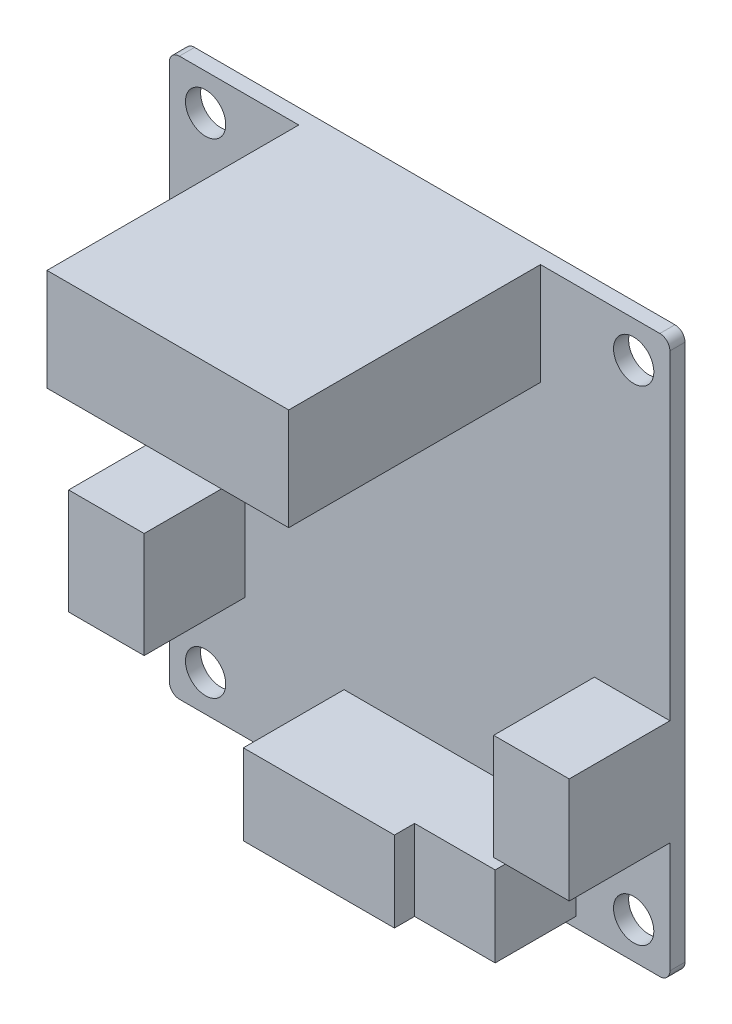
from build123d import *

# Parameters (mm, degrees)
ESQUISSE1_W        = 49.7
ESQUISSE1_H        = 55.3
ESQUISSE1_R        = 2
BOSS_EXTRU_1_DEPTH = 1.5
CONG_1_R           = 1
ESQUISSE2_W        = 24
ESQUISSE2_H        = 10.127456192
BOSS_EXTRU_2_DEPTH = 25
ESQUISSE3_W        = 7.5
ESQUISSE3_H        = 10.5
BOSS_EXTRU_3_DEPTH = 10
ESQUISSE4_W        = 15
ESQUISSE4_H        = 8
BOSS_EXTRU_4_DEPTH = 10
ESQUISSE5_W        = 8
ESQUISSE5_H        = 8
BOSS_EXTRU_5_DEPTH = 8


with BuildPart() as part:
    # Esquisse1 → Boss.-Extru.1 (new body)
    with BuildSketch(Plane.XY):
        with Locations((24.85, 27.65)):
            Rectangle(ESQUISSE1_W, ESQUISSE1_H)
        with Locations((3.6, 51.7)):
            Circle(ESQUISSE1_R, mode=Mode.SUBTRACT)
        with Locations((46.1, 51.7)):
            Circle(ESQUISSE1_R, mode=Mode.SUBTRACT)
        with Locations((46.1, 3.6)):
            Circle(ESQUISSE1_R, mode=Mode.SUBTRACT)
        with Locations((3.6, 3.6)):
            Circle(ESQUISSE1_R, mode=Mode.SUBTRACT)
    extrude(amount=BOSS_EXTRU_1_DEPTH)

    # Congé1
    cong_1_edges = [part.edges().sort_by_distance(p)[0] for p in [
        (0, 55.3, 0.75),
        (49.7, 55.3, 0.75),
        (49.7, 0, 0.75),
        (0, 0, 0.75),
    ]]
    fillet(cong_1_edges, radius=CONG_1_R)

    # Esquisse2 → Boss.-Extru.2 (add)
    with BuildSketch(Plane.XY.offset(1.5)):
        with Locations((24.85, 50.236271904)):
            Rectangle(ESQUISSE2_W, ESQUISSE2_H)
    extrude(amount=BOSS_EXTRU_2_DEPTH)

    # Esquisse3 → Boss.-Extru.3 (add)
    with BuildSketch(Plane.XY.offset(1.5)):
        with Locations((3.75, 17.25)):
            Rectangle(ESQUISSE3_W, ESQUISSE3_H)
        with Locations((45.95, 17.25)):
            Rectangle(ESQUISSE3_W, ESQUISSE3_H)
    extrude(amount=BOSS_EXTRU_3_DEPTH)

    # Esquisse4 → Boss.-Extru.4 (add)
    with BuildSketch(Plane.XY.offset(1.5)):
        with Locations((24.85, 5)):
            Rectangle(ESQUISSE4_W, ESQUISSE4_H)
    extrude(amount=BOSS_EXTRU_4_DEPTH)

    # Esquisse5 → Boss.-Extru.5 (add)
    with BuildSketch(Plane.XY.offset(1.5)):
        with Locations((36.35, 5)):
            Rectangle(ESQUISSE5_W, ESQUISSE5_H)
    extrude(amount=BOSS_EXTRU_5_DEPTH)


solid = part.part
